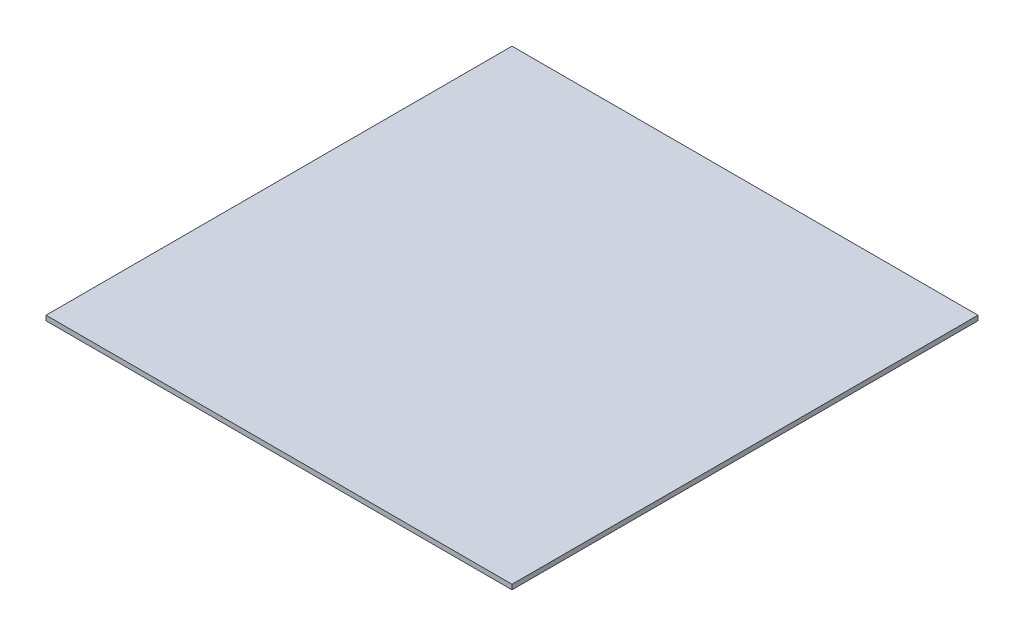
from build123d import *

# Parameters (mm, degrees)
SKETCH1_W           = 609.6
SKETCH1_H           = 609.6
BOSS_EXTRUDE1_DEPTH = 6.35


with BuildPart() as part:
    # Sketch1 → Boss-Extrude1 (new body)
    with BuildSketch(Plane(origin=(0, 0, 0), x_dir=(1, 0, 0), z_dir=(0, 1, 0))):
        Rectangle(SKETCH1_W, SKETCH1_H)
    extrude(amount=BOSS_EXTRUDE1_DEPTH)


solid = part.part
